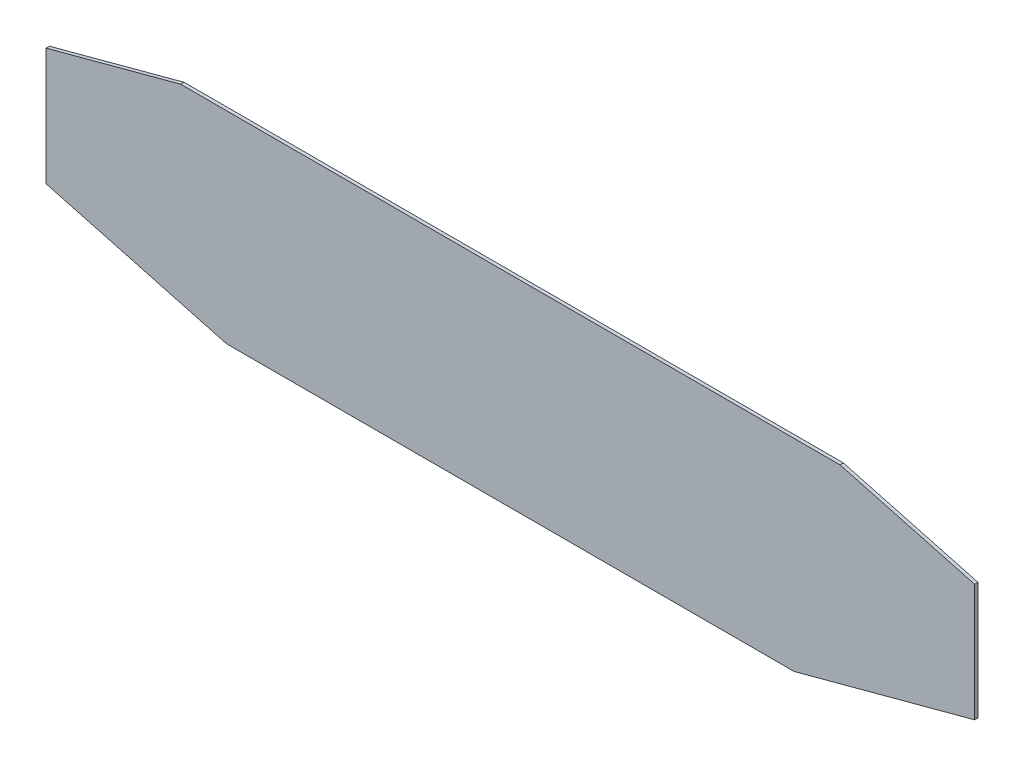
from build123d import *

# Parameters (mm, degrees)
AUFSATZ_LINEAR_AUSTRAGEN1_DEPTH = 1.5


with BuildPart() as part:
    # Skizze1 → Aufsatz-Linear austragen1 (new body)
    with BuildSketch(Plane.XY):
        Polygon((-147, 90), (-126.5, 0), (126.5, 0), (147, 90), align=None)
        Polygon((-207, 21.569909991), (-126.5, 0), (-147, 90), (-207, 73.923048454), align=None)
        Polygon((147, 90), (126.5, 0), (207, 21.569909991), (207, 73.923048454), align=None)
    extrude(amount=AUFSATZ_LINEAR_AUSTRAGEN1_DEPTH)


solid = part.part
